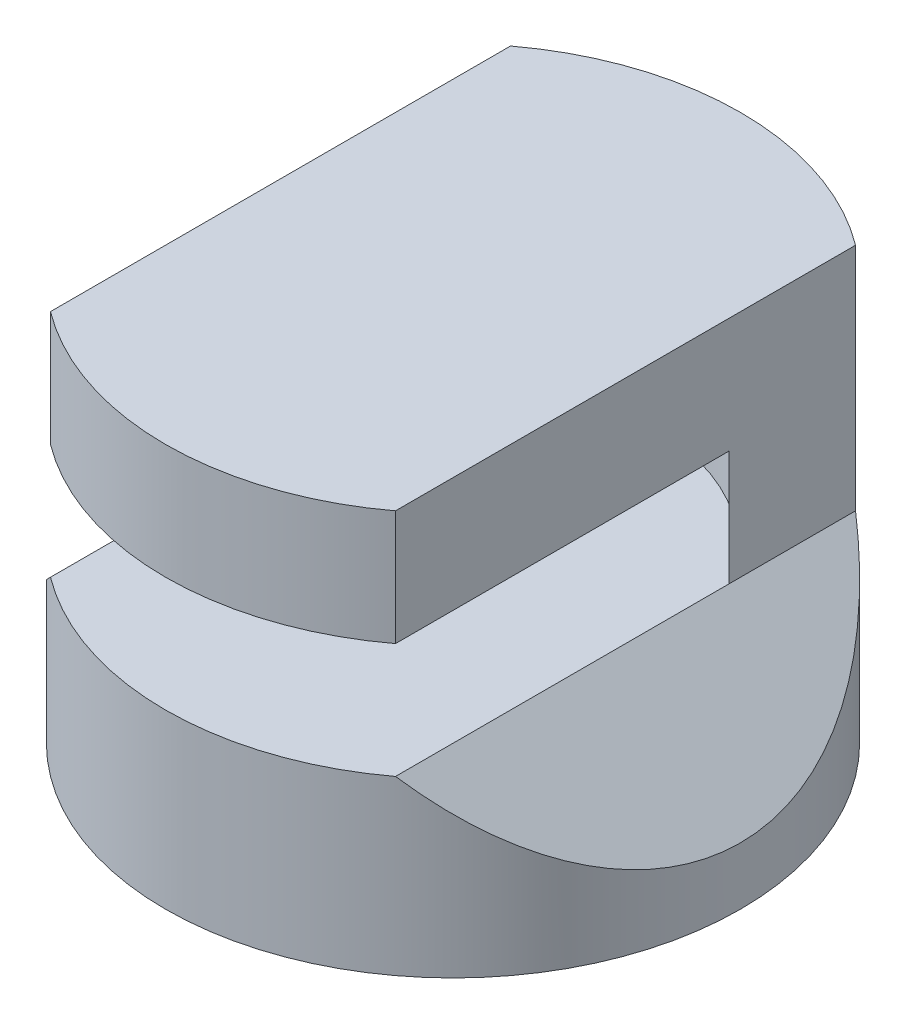
from build123d import *

# Parameters (mm, degrees)
SKETCH1_W           = 100
SKETCH1_H           = 80
BOSS_EXTRUDE2_DEPTH = 100
SKETCH2_W           = 20
SKETCH2_H           = 10
CUT_EXTRUDE1_DEPTH  = 100
CUT_EXTRUDE2_DEPTH  = 100
SKETCH4_W           = 15
SKETCH4_H           = 10
CUT_EXTRUDE5_DEPTH  = 100
SKETCH7_R           = 35
CUT_EXTRUDE16_DEPTH = 20
BOSS_EXTRUDE3_DEPTH = 40
CUT_EXTRUDE17_DEPTH = 10
SKETCH18_W          = 60
SKETCH18_H          = 20
CUT_EXTRUDE22_DEPTH = 75


with BuildPart() as part:
    # Sketch1 → Boss-Extrude2 (new body)
    with BuildSketch(Plane.XY):
        with Locations((50, 40)):
            Rectangle(SKETCH1_W, SKETCH1_H)
    extrude(amount=BOSS_EXTRUDE2_DEPTH)

    # Sketch2 → Cut-Extrude1 (cut)
    with BuildSketch(Plane.XY):
        Polygon((0, 80), (20, 80), (20, 40), (0, 20), align=None)
        with Locations((10, 5)):
            Rectangle(SKETCH2_W, SKETCH2_H)
        with Locations((90, 5)):
            Rectangle(SKETCH2_W, SKETCH2_H)
        Polygon((80, 80), (100, 80), (100, 20), (80, 40), align=None)
    extrude(amount=CUT_EXTRUDE1_DEPTH, mode=Mode.SUBTRACT)

    # Sketch3 → Cut-Extrude2 (cut)
    with BuildSketch(Plane(origin=(0, 80, 0), x_dir=(1, 0, 0), z_dir=(0, 1, 0))):
        with BuildLine():
            Line((0, 0), (0, -50))
            ThreePointArc((0, -50), (14.644660941, -14.644660941), (50, 0))
            Line((50, 0), (0, 0))
        make_face()
        with BuildLine():
            Line((100, 0), (50, 0))
            ThreePointArc((50, 0), (85.355339059, -14.644660941), (100, -50))
            Line((100, -50), (100, 0))
        make_face()
        with BuildLine():
            ThreePointArc((100, -50), (85.355339059, -85.355339059), (50, -100))
            Line((50, -100), (100, -100))
            Line((100, -100), (100, -50))
        make_face()
        with BuildLine():
            ThreePointArc((50, -100), (14.644660941, -85.355339059), (0, -50))
            Line((0, -50), (0, -100))
            Line((0, -100), (50, -100))
        make_face()
    extrude(amount=-CUT_EXTRUDE2_DEPTH, mode=Mode.SUBTRACT)

    # Sketch4 → Cut-Extrude5 (cut)
    with BuildSketch(Plane(origin=(0, 0, 0), x_dir=(0, 0, -1), z_dir=(1, 0, 0))):
        with Locations((-7.5, 5)):
            Rectangle(SKETCH4_W, SKETCH4_H)
        with Locations((-92.5, 5)):
            Rectangle(SKETCH4_W, SKETCH4_H)
    extrude(amount=CUT_EXTRUDE5_DEPTH, mode=Mode.SUBTRACT)

    # Sketch7 → Cut-Extrude16 (cut)
    with BuildSketch(Plane(origin=(0, 60, 0), x_dir=(1, 0, 0), z_dir=(0, 1, 0))):
        with BuildLine():
            Line((15, -85), (50, -85))
            ThreePointArc((50, -85), (25.251262658, -74.748737342), (15, -50))
            Line((15, -50), (15, -85))
        make_face()
        with BuildLine():
            ThreePointArc((50, -15), (74.748737342, -25.251262658), (85, -50))
            Line((85, -50), (85, -15))
            Line((85, -15), (50, -15))
        make_face()
        with BuildLine():
            ThreePointArc((85, -50), (74.748737342, -74.748737342), (50, -85))
            Line((50, -85), (85, -85))
            Line((85, -85), (85, -50))
        make_face()
        with BuildLine():
            Line((15, -15), (15, -50))
            ThreePointArc((15, -50), (25.251262658, -25.251262658), (50, -15))
            Line((50, -15), (15, -15))
        make_face()
        with Locations((50, -50)):
            Circle(SKETCH7_R)
    extrude(amount=-CUT_EXTRUDE16_DEPTH, mode=Mode.SUBTRACT)

    # Sketch8 → Boss-Extrude3 (add)
    with BuildSketch(Plane(origin=(0, 80, 0), x_dir=(1, 0, 0), z_dir=(0, 1, 0))):
        with BuildLine():
            ThreePointArc((20, -31.972243623), (32.765898242, -19.537141687), (50, -15))
            Line((50, -15), (20, -15))
            Line((20, -15), (20, -31.972243623))
        make_face()
        with BuildLine():
            Line((80, -15), (50, -15))
            ThreePointArc((50, -15), (67.234101758, -19.537141687), (80, -31.972243623))
            Line((80, -31.972243623), (80, -15))
        make_face()
        with BuildLine():
            ThreePointArc((50, -85), (32.765898242, -80.462858313), (20, -68.027756377))
            Line((20, -68.027756377), (20, -85))
            Line((20, -85), (50, -85))
        make_face()
        with BuildLine():
            Line((80, -85), (80, -68.027756377))
            ThreePointArc((80, -68.027756377), (67.234101758, -80.462858313), (50, -85))
            Line((50, -85), (80, -85))
        make_face()
    extrude(amount=-BOSS_EXTRUDE3_DEPTH)

    # Sketch9 → Cut-Extrude17 (cut)
    with BuildSketch(Plane.XZ):
        with BuildLine():
            Line((20, 85), (20, 68.027756377))
            ThreePointArc((20, 68.027756377), (32.765898242, 80.462858313), (50, 85))
            Line((50, 85), (20, 85))
        make_face()
        with BuildLine():
            Line((80, 85), (50, 85))
            ThreePointArc((50, 85), (67.234101758, 80.462858313), (80, 68.027756377))
            Line((80, 68.027756377), (80, 85))
        make_face()
        with BuildLine():
            ThreePointArc((80, 31.972243623), (67.234101758, 19.537141687), (50, 15))
            Line((50, 15), (80, 15))
            Line((80, 15), (80, 31.972243623))
        make_face()
        with BuildLine():
            ThreePointArc((50, 15), (32.765898242, 19.537141687), (20, 31.972243623))
            Line((20, 31.972243623), (20, 15))
            Line((20, 15), (50, 15))
        make_face()
    extrude(amount=-CUT_EXTRUDE17_DEPTH, mode=Mode.SUBTRACT)

    # Sketch18 → Cut-Extrude22 (cut)
    with BuildSketch(Plane.XY.offset(50)):
        with Locations((50, 50)):
            Rectangle(SKETCH18_W, SKETCH18_H)
    extrude(amount=CUT_EXTRUDE22_DEPTH, mode=Mode.SUBTRACT)


solid = part.part
